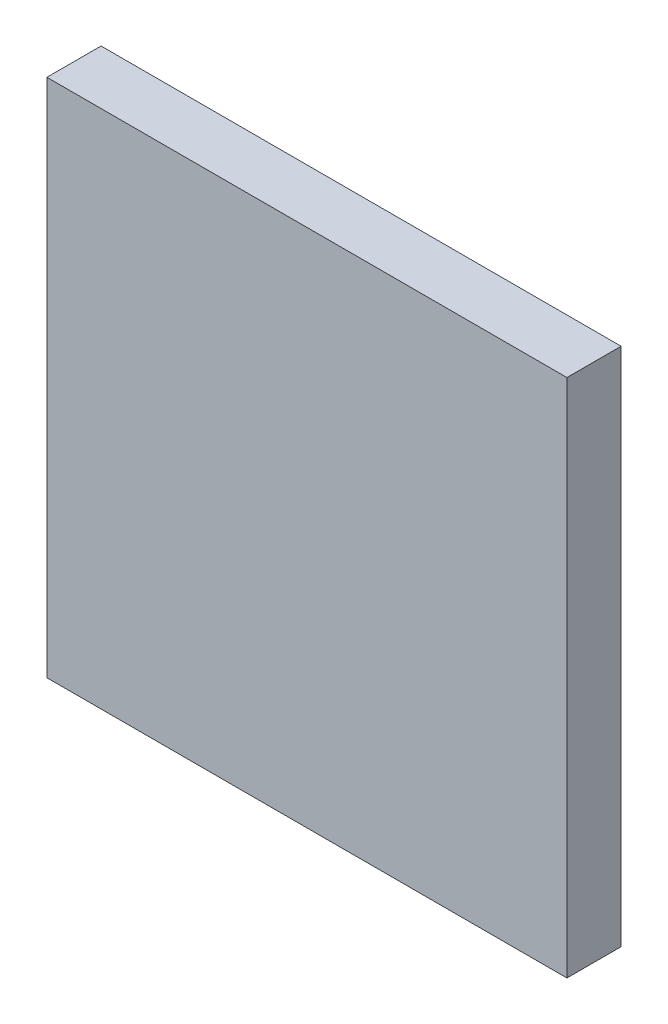
from build123d import *

# Parameters (mm, degrees)
SKETCH1_W           = 48
SKETCH1_H           = 48
BOSS_EXTRUDE1_DEPTH = 5


with BuildPart() as part:
    # Sketch1 → Boss-Extrude1 (new body)
    with BuildSketch(Plane.XY):
        Rectangle(SKETCH1_W, SKETCH1_H)
    extrude(amount=BOSS_EXTRUDE1_DEPTH)


solid = part.part
